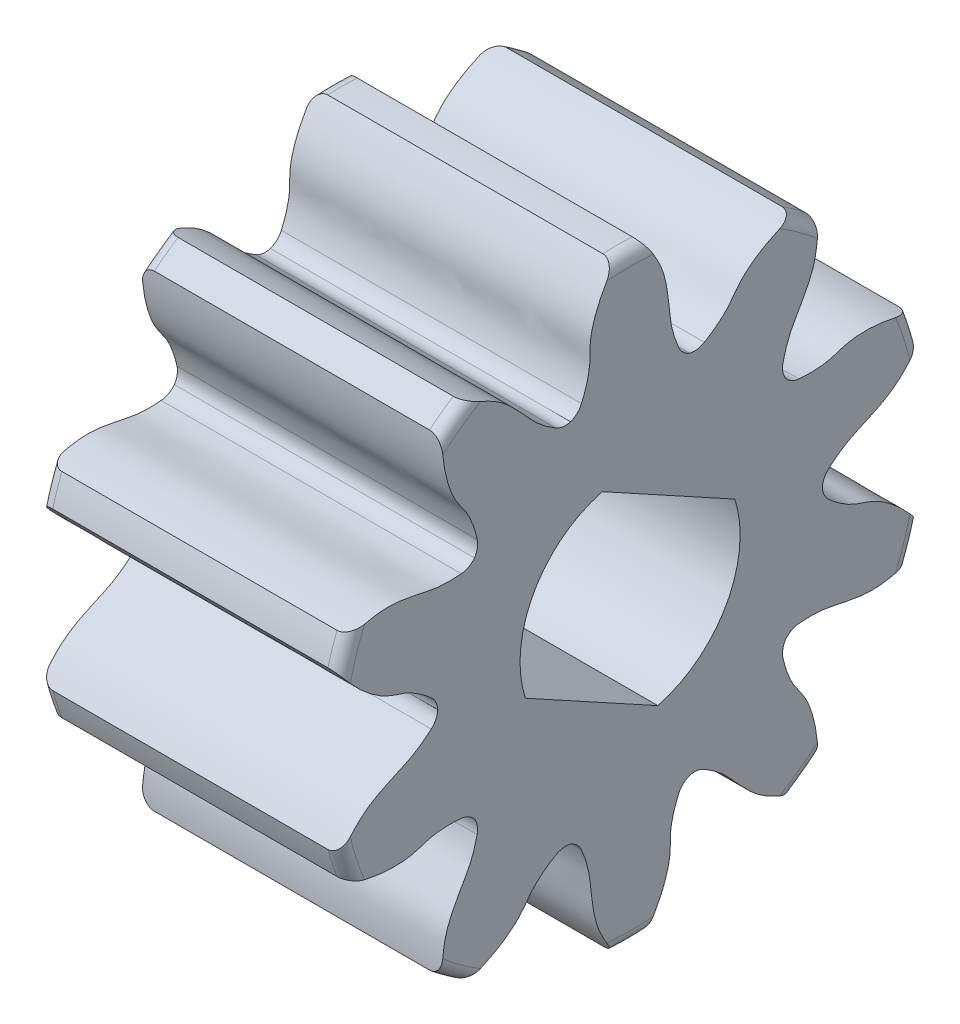
from build123d import *

# Parameters (mm, degrees)
SKETCH1_W           = 2.4
SKETCH1_H           = 2.4
CUT_EXTRUDE1_DEPTH  = 5.156921938
CUT_EXTRUDE2_DEPTH  = 5.156922111
CUT_EXTRUDE3_DEPTH  = 5.156922111
CUT_EXTRUDE4_DEPTH  = 5.156922111
CUT_EXTRUDE5_DEPTH  = 5.156922111
CUT_EXTRUDE6_DEPTH  = 5.156922111
CUT_EXTRUDE7_DEPTH  = 5.156922111
CUT_EXTRUDE8_DEPTH  = 5.156922111
CUT_EXTRUDE9_DEPTH  = 5.109057333
CUT_EXTRUDE10_DEPTH = 5.109057333
FILLET1_R           = 0.1
SCALE1_SCALE        = 2.5
CUT_EXTRUDE11_START = -6
CUT_EXTRUDE11_DEPTH = 6.000049


with BuildPart() as part:
    # Sketch1 → Revolve1 (revolve)
    with BuildSketch(Plane.XY, mode=Mode.PRIVATE) as revolve1_sk:
        with Locations((-0.8, 1.2)):
            Rectangle(SKETCH1_W, SKETCH1_H)
    revolve(revolve1_sk.sketch.rotate(Axis((-2, 0, 0), (1, 0, 0)), 270), axis=Axis((-2, 0, 0), (1, 0, 0)))

    # Sketch2 → Cut-Extrude1 (cut, through all)
    with BuildSketch(Plane.ZY.offset(2)):
        with BuildLine():
            ThreePointArc((1.313937156, 2.008374753), (0.741640786, 2.282535639), (0.117495572, 2.397122189))
            add(Edge.make_bspline(
                [(0.117495572, 2.397122189), (0.141774305, 2.363264737), (0.164667851, 2.32835723), (0.185846891, 2.292479211), (0.240081832, 2.200603365), (0.285141165, 2.100907601), (0.308300652, 1.996762327), (0.31987732, 1.944703519), (0.322889285, 1.890583293), (0.321092337, 1.837283109), (0.319288686, 1.783784122), (0.32833626, 1.729839367), (0.341837087, 1.678040503), (0.353675808, 1.632618674), (0.369800189, 1.588226107), (0.388574435, 1.545204885)],
                knots=[-0.000124084, -0.000124084, -0.000124084, -0.000124084, 0, 0, 0, 0.000320068, 0.000320068, 0.000320068, 0.000479179, 0.000479179, 0.000479179, 0.00063999, 0.00063999, 0.00063999, 0.000780383, 0.000780383, 0.000780383, 0.000780383], degree=3))
            ThreePointArc((0.388574435, 1.545204885), (0.423536077, 1.495046185), (0.475090004, 1.462176683))
            ThreePointArc((0.475090004, 1.462176683), (0.536118215, 1.45846603), (0.593885321, 1.478495334))
            add(Edge.make_bspline(
                [(0.593885321, 1.478495334), (0.660752303, 1.51776328), (0.724427265, 1.564713522), (0.777754321, 1.621010856), (0.876765521, 1.725536908), (0.96863274, 1.845157982), (1.095037654, 1.914083385), (1.128282244, 1.93221082), (1.162392991, 1.948826333), (1.197132178, 1.963892703), (1.235354952, 1.980469902), (1.274394337, 1.99525418), (1.313937156, 2.008374753)],
                knots=[0, 0, 0, 0, 0.000232634, 0.000232634, 0.000232634, 0.000660459, 0.000660459, 0.000660459, 0.000769687, 0.000769687, 0.000769687, 0.000890052, 0.000890052, 0.000890052, 0.000890052], degree=3))
        make_face()
    extrude(amount=-CUT_EXTRUDE1_DEPTH, mode=Mode.SUBTRACT)

    # Sketch3 → Cut-Extrude2 (cut, through all)
    with BuildSketch(Plane.ZY.offset(2)):
        with BuildLine():
            ThreePointArc((2.24349055, 0.852496424), (1.941640786, 1.410684605), (1.504048986, 1.870250424))
            add(Edge.make_bspline(
                [(1.504048986, 1.870250424), (1.503789982, 1.828588488), (1.501793131, 1.786891234), (1.497838764, 1.745416579), (1.487712486, 1.63920896), (1.465566552, 1.532068181), (1.423087915, 1.43420008), (1.401854237, 1.385279025), (1.372479897, 1.339724453), (1.339697073, 1.297659918), (1.306791974, 1.255438488), (1.282403683, 1.206478234), (1.262879473, 1.156636485), (1.245758918, 1.112930828), (1.232710521, 1.067538814), (1.222611965, 1.021698689)],
                knots=[-0.000124067, -0.000124067, -0.000124067, -0.000124067, 0, 0, 0, 0.000320068, 0.000320068, 0.000320068, 0.000479179, 0.000479179, 0.000479179, 0.00063999, 0.00063999, 0.00063999, 0.000780383, 0.000780383, 0.000780383, 0.000780383], degree=3))
            ThreePointArc((1.222611965, 1.021698689), (1.221413983, 0.960569511), (1.243801777, 0.903674887))
            ThreePointArc((1.243801777, 0.903674887), (1.290993571, 0.864801424), (1.349501071, 0.847050818))
            add(Edge.make_bspline(
                [(1.349501071, 0.847050818), (1.426678715, 0.839515828), (1.5057895, 0.840072168), (1.582022738, 0.854272811), (1.723563354, 0.88063884), (1.868196998, 0.923416125), (2.010974057, 0.904879004), (2.048524534, 0.900003726), (2.085887061, 0.893396165), (2.122847445, 0.885165932), (2.163514151, 0.876110385), (2.203787658, 0.865124342), (2.24349055, 0.852496424)],
                knots=[0, 0, 0, 0, 0.000232634, 0.000232634, 0.000232634, 0.000660459, 0.000660459, 0.000660459, 0.000769687, 0.000769687, 0.000769687, 0.000890048, 0.000890048, 0.000890048, 0.000890048], degree=3))
        make_face()
    extrude(amount=-CUT_EXTRUDE2_DEPTH, mode=Mode.SUBTRACT)

    # Sketch4 → Cut-Extrude3 (cut, through all)
    with BuildSketch(Plane.ZY.offset(2)):
        with BuildLine():
            ThreePointArc((2.316106807, -0.629006564), (2.4, 0), (2.316106807, 0.629006564))
            add(Edge.make_bspline(
                [(2.316106807, 0.629006564), (2.291408997, 0.595453589), (2.26528448, 0.56289352), (2.23770714, 0.531664139), (2.167087536, 0.451692447), (2.08619533, 0.378030789), (1.994303963, 0.323822149), (1.948370482, 0.296725027), (1.897829837, 0.277136408), (1.846583062, 0.262374745), (1.795145143, 0.247558023), (1.746636486, 0.222283423), (1.701544824, 0.193436643), (1.662004463, 0.168141233), (1.624767332, 0.139087979), (1.589653279, 0.107938321)],
                knots=[-0.000124063, -0.000124063, -0.000124063, -0.000124063, 0, 0, 0, 0.000320068, 0.000320068, 0.000320068, 0.000479179, 0.000479179, 0.000479179, 0.00063999, 0.00063999, 0.00063999, 0.000780383, 0.000780383, 0.000780383, 0.000780383], degree=3))
            ThreePointArc((1.589653279, 0.107938321), (1.552753262, 0.059187933), (1.537423547, 0))
            ThreePointArc((1.537423547, 0), (1.552753262, -0.059187933), (1.589653279, -0.107938321))
            add(Edge.make_bspline(
                [(1.589653279, -0.107938321), (1.647662348, -0.159398136), (1.711991327, -0.205448201), (1.78201224, -0.238768412), (1.912018567, -0.300633333), (2.0541735, -0.351039306), (2.158786721, -0.449958402), (2.186300079, -0.475974201), (2.212643171, -0.503280972), (2.23770714, -0.531664139), (2.26528448, -0.56289352), (2.291408997, -0.595453589), (2.316106807, -0.629006564)],
                knots=[0, 0, 0, 0, 0.000232634, 0.000232634, 0.000232634, 0.000660459, 0.000660459, 0.000660459, 0.000769687, 0.000769687, 0.000769687, 0.00089005, 0.00089005, 0.00089005, 0.00089005], degree=3))
        make_face()
    extrude(amount=-CUT_EXTRUDE3_DEPTH, mode=Mode.SUBTRACT)

    # Sketch5 → Cut-Extrude4 (cut, through all)
    with BuildSketch(Plane.ZY.offset(2)):
        with BuildLine():
            ThreePointArc((1.504048986, -1.870250424), (1.941640786, -1.410684606), (2.24349055, -0.852496424))
            add(Edge.make_bspline(
                [(2.24349055, -0.852496424), (2.203787658, -0.865124342), (2.163514151, -0.876110385), (2.122847445, -0.885165932), (2.018708804, -0.908355228), (1.909968398, -0.920401515), (1.803763682, -0.910244837), (1.750675426, -0.905167846), (1.698273284, -0.891308326), (1.648137084, -0.873128663), (1.597813883, -0.854881194), (1.543713518, -0.846816101), (1.490277886, -0.843649422), (1.443420793, -0.840872598), (1.396218246, -0.842489738), (1.349501071, -0.847050818)],
                knots=[-0.000124065, -0.000124065, -0.000124065, -0.000124065, 0, 0, 0, 0.000320068, 0.000320068, 0.000320068, 0.000479179, 0.000479179, 0.000479179, 0.00063999, 0.00063999, 0.00063999, 0.000780383, 0.000780383, 0.000780383, 0.000780383], degree=3))
            ThreePointArc((1.349501071, -0.847050818), (1.290993571, -0.864801424), (1.243801777, -0.903674887))
            ThreePointArc((1.243801777, -0.903674887), (1.221413983, -0.960569511), (1.222611965, -1.021698689))
            add(Edge.make_bspline(
                [(1.222611965, -1.021698689), (1.239294967, -1.09742743), (1.264270655, -1.17249434), (1.301333635, -1.240608218), (1.370147675, -1.367073791), (1.455525544, -1.491409653), (1.482016232, -1.632926991), (1.488983303, -1.670146161), (1.494244795, -1.707721884), (1.497838764, -1.745416579), (1.501793131, -1.786891234), (1.503789982, -1.828588488), (1.504048986, -1.870250424)],
                knots=[0, 0, 0, 0, 0.000232634, 0.000232634, 0.000232634, 0.000660459, 0.000660459, 0.000660459, 0.000769687, 0.000769687, 0.000769687, 0.000890052, 0.000890052, 0.000890052, 0.000890052], degree=3))
        make_face()
    extrude(amount=-CUT_EXTRUDE4_DEPTH, mode=Mode.SUBTRACT)

    # Sketch6 → Cut-Extrude5 (cut, through all)
    with BuildSketch(Plane.ZY.offset(2)):
        with BuildLine():
            ThreePointArc((0.117495572, -2.397122189), (0.741640786, -2.282535639), (1.313937156, -2.008374753))
            add(Edge.make_bspline(
                [(1.313937156, -2.008374753), (1.274394337, -1.99525418), (1.235354952, -1.980469902), (1.197132178, -1.963892703), (1.099251922, -1.92144208), (1.004198456, -1.867271724), (0.924246981, -1.796629232), (0.884281861, -1.761317367), (0.850034059, -1.719303573), (0.820158758, -1.675126599), (0.790172027, -1.63078485), (0.751144455, -1.592460657), (0.709775447, -1.558490083), (0.673499439, -1.528701677), (0.634361246, -1.502265009), (0.593885321, -1.478495334)],
                knots=[-0.000124067, -0.000124067, -0.000124067, -0.000124067, 0, 0, 0, 0.000320068, 0.000320068, 0.000320068, 0.000479179, 0.000479179, 0.000479179, 0.00063999, 0.00063999, 0.00063999, 0.000780383, 0.000780383, 0.000780383, 0.000780383], degree=3))
            ThreePointArc((0.593885321, -1.478495334), (0.536118215, -1.45846603), (0.475090004, -1.462176683))
            ThreePointArc((0.475090004, -1.462176683), (0.423536077, -1.495046185), (0.388574435, -1.545204885))
            add(Edge.make_bspline(
                [(0.388574435, -1.545204885), (0.357559031, -1.616276746), (0.333641564, -1.691687493), (0.323589812, -1.76857785), (0.30492694, -1.911338526), (0.300916302, -2.062112204), (0.239165914, -2.192172971), (0.222925514, -2.226379054), (0.205095694, -2.25987108), (0.185846891, -2.292479211), (0.164667851, -2.32835723), (0.141774305, -2.363264737), (0.117495572, -2.397122189)],
                knots=[0, 0, 0, 0, 0.000232634, 0.000232634, 0.000232634, 0.000660459, 0.000660459, 0.000660459, 0.000769687, 0.000769687, 0.000769687, 0.000890069, 0.000890069, 0.000890069, 0.000890069], degree=3))
        make_face()
    extrude(amount=-CUT_EXTRUDE5_DEPTH, mode=Mode.SUBTRACT)

    # Sketch7 → Cut-Extrude6 (cut, through all)
    with BuildSketch(Plane.ZY.offset(2)):
        with BuildLine():
            ThreePointArc((-1.313937156, -2.008374753), (-0.741640786, -2.282535639), (-0.117495572, -2.397122189))
            add(Edge.make_bspline(
                [(-0.117495572, -2.397122189), (-0.141774305, -2.363264737), (-0.164667851, -2.32835723), (-0.185846891, -2.292479211), (-0.240081832, -2.200603365), (-0.285141165, -2.100907601), (-0.308300652, -1.996762327), (-0.31987732, -1.944703519), (-0.322889285, -1.890583293), (-0.321092337, -1.837283109), (-0.319288686, -1.783784122), (-0.32833626, -1.729839367), (-0.341837087, -1.678040503), (-0.353675808, -1.632618674), (-0.369800189, -1.588226107), (-0.388574435, -1.545204885)],
                knots=[-0.000124084, -0.000124084, -0.000124084, -0.000124084, 0, 0, 0, 0.000320068, 0.000320068, 0.000320068, 0.000479179, 0.000479179, 0.000479179, 0.00063999, 0.00063999, 0.00063999, 0.000780383, 0.000780383, 0.000780383, 0.000780383], degree=3))
            ThreePointArc((-0.388574435, -1.545204885), (-0.423536077, -1.495046185), (-0.475090004, -1.462176683))
            ThreePointArc((-0.475090004, -1.462176683), (-0.536118215, -1.45846603), (-0.593885321, -1.478495334))
            add(Edge.make_bspline(
                [(-0.593885321, -1.478495334), (-0.660752303, -1.51776328), (-0.724427265, -1.564713522), (-0.777754321, -1.621010856), (-0.876765521, -1.725536908), (-0.96863274, -1.845157982), (-1.095037654, -1.914083385), (-1.128282244, -1.93221082), (-1.162392991, -1.948826333), (-1.197132178, -1.963892703), (-1.235354952, -1.980469902), (-1.274394337, -1.99525418), (-1.313937156, -2.008374753)],
                knots=[0, 0, 0, 0, 0.000232634, 0.000232634, 0.000232634, 0.000660459, 0.000660459, 0.000660459, 0.000769687, 0.000769687, 0.000769687, 0.000890052, 0.000890052, 0.000890052, 0.000890052], degree=3))
        make_face()
    extrude(amount=-CUT_EXTRUDE6_DEPTH, mode=Mode.SUBTRACT)

    # Sketch8 → Cut-Extrude7 (cut, through all)
    with BuildSketch(Plane.ZY.offset(2)):
        with BuildLine():
            ThreePointArc((-2.24349055, -0.852496424), (-1.941640786, -1.410684605), (-1.504048986, -1.870250424))
            add(Edge.make_bspline(
                [(-1.504048986, -1.870250424), (-1.503789982, -1.828588488), (-1.501793131, -1.786891234), (-1.497838764, -1.745416579), (-1.487712486, -1.63920896), (-1.465566552, -1.532068181), (-1.423087915, -1.43420008), (-1.401854237, -1.385279025), (-1.372479897, -1.339724453), (-1.339697073, -1.297659918), (-1.306791974, -1.255438488), (-1.282403683, -1.206478234), (-1.262879473, -1.156636485), (-1.245758918, -1.112930828), (-1.232710521, -1.067538814), (-1.222611965, -1.021698689)],
                knots=[-0.000124067, -0.000124067, -0.000124067, -0.000124067, 0, 0, 0, 0.000320068, 0.000320068, 0.000320068, 0.000479179, 0.000479179, 0.000479179, 0.00063999, 0.00063999, 0.00063999, 0.000780383, 0.000780383, 0.000780383, 0.000780383], degree=3))
            ThreePointArc((-1.222611965, -1.021698689), (-1.221413983, -0.960569511), (-1.243801777, -0.903674887))
            ThreePointArc((-1.243801777, -0.903674887), (-1.290993571, -0.864801424), (-1.349501071, -0.847050818))
            add(Edge.make_bspline(
                [(-1.349501071, -0.847050818), (-1.426678715, -0.839515828), (-1.505789501, -0.840072168), (-1.582022738, -0.854272811), (-1.723563354, -0.88063884), (-1.868196998, -0.923416125), (-2.010974057, -0.904879004), (-2.048524534, -0.900003726), (-2.085887061, -0.893396165), (-2.122847445, -0.885165932), (-2.163514151, -0.876110385), (-2.203787658, -0.865124342), (-2.24349055, -0.852496424)],
                knots=[0, 0, 0, 0, 0.000232634, 0.000232634, 0.000232634, 0.000660459, 0.000660459, 0.000660459, 0.000769687, 0.000769687, 0.000769687, 0.000890048, 0.000890048, 0.000890048, 0.000890048], degree=3))
        make_face()
    extrude(amount=-CUT_EXTRUDE7_DEPTH, mode=Mode.SUBTRACT)

    # Sketch9 → Cut-Extrude8 (cut, through all)
    with BuildSketch(Plane.ZY.offset(2)):
        with BuildLine():
            ThreePointArc((-2.316106807, 0.629006564), (-2.4, 0), (-2.316106807, -0.629006564))
            add(Edge.make_bspline(
                [(-2.316106807, -0.629006564), (-2.291408997, -0.595453589), (-2.26528448, -0.56289352), (-2.23770714, -0.531664139), (-2.167087536, -0.451692447), (-2.08619533, -0.378030789), (-1.994303963, -0.323822149), (-1.948370482, -0.296725027), (-1.897829837, -0.277136408), (-1.846583062, -0.262374745), (-1.795145143, -0.247558023), (-1.746636486, -0.222283423), (-1.701544824, -0.193436643), (-1.662004463, -0.168141233), (-1.624767332, -0.139087979), (-1.589653279, -0.107938321)],
                knots=[-0.000124063, -0.000124063, -0.000124063, -0.000124063, 0, 0, 0, 0.000320068, 0.000320068, 0.000320068, 0.000479179, 0.000479179, 0.000479179, 0.00063999, 0.00063999, 0.00063999, 0.000780383, 0.000780383, 0.000780383, 0.000780383], degree=3))
            ThreePointArc((-1.589653279, -0.107938321), (-1.552753262, -0.059187933), (-1.537423547, 0))
            ThreePointArc((-1.537423547, 0), (-1.552753262, 0.059187933), (-1.589653279, 0.107938321))
            add(Edge.make_bspline(
                [(-1.589653279, 0.107938321), (-1.647662348, 0.159398136), (-1.711991327, 0.205448201), (-1.78201224, 0.238768412), (-1.912018567, 0.300633333), (-2.0541735, 0.351039306), (-2.158786721, 0.449958402), (-2.186300079, 0.475974201), (-2.212643171, 0.503280972), (-2.23770714, 0.531664139), (-2.26528448, 0.56289352), (-2.291408997, 0.595453589), (-2.316106807, 0.629006564)],
                knots=[0, 0, 0, 0, 0.000232634, 0.000232634, 0.000232634, 0.000660459, 0.000660459, 0.000660459, 0.000769687, 0.000769687, 0.000769687, 0.00089005, 0.00089005, 0.00089005, 0.00089005], degree=3))
        make_face()
    extrude(amount=-CUT_EXTRUDE8_DEPTH, mode=Mode.SUBTRACT)

    # Sketch10 → Cut-Extrude9 (cut, through all)
    with BuildSketch(Plane.ZY.offset(2)):
        with BuildLine():
            ThreePointArc((-1.504048986, 1.870250424), (-1.941640786, 1.410684606), (-2.24349055, 0.852496424))
            add(Edge.make_bspline(
                [(-2.24349055, 0.852496424), (-2.203787658, 0.865124342), (-2.163514151, 0.876110385), (-2.122847445, 0.885165932), (-2.018708804, 0.908355228), (-1.909968398, 0.920401515), (-1.803763682, 0.910244837), (-1.750675426, 0.905167846), (-1.698273284, 0.891308326), (-1.648137084, 0.873128663), (-1.597813883, 0.854881194), (-1.543713518, 0.846816101), (-1.490277886, 0.843649422), (-1.443420793, 0.840872598), (-1.396218246, 0.842489738), (-1.349501071, 0.847050818)],
                knots=[-0.000124065, -0.000124065, -0.000124065, -0.000124065, 0, 0, 0, 0.000320068, 0.000320068, 0.000320068, 0.000479179, 0.000479179, 0.000479179, 0.00063999, 0.00063999, 0.00063999, 0.000780383, 0.000780383, 0.000780383, 0.000780383], degree=3))
            ThreePointArc((-1.349501071, 0.847050818), (-1.290993571, 0.864801424), (-1.243801777, 0.903674887))
            ThreePointArc((-1.243801777, 0.903674887), (-1.221413983, 0.960569511), (-1.222611965, 1.021698689))
            add(Edge.make_bspline(
                [(-1.222611965, 1.021698689), (-1.239294967, 1.09742743), (-1.264270655, 1.17249434), (-1.301333635, 1.240608218), (-1.370147675, 1.367073791), (-1.455525544, 1.491409653), (-1.482016232, 1.632926991), (-1.488983303, 1.670146161), (-1.494244795, 1.707721884), (-1.497838764, 1.745416579), (-1.501793131, 1.786891234), (-1.503789982, 1.828588488), (-1.504048986, 1.870250424)],
                knots=[0, 0, 0, 0, 0.000232634, 0.000232634, 0.000232634, 0.000660459, 0.000660459, 0.000660459, 0.000769687, 0.000769687, 0.000769687, 0.000890052, 0.000890052, 0.000890052, 0.000890052], degree=3))
        make_face()
    extrude(amount=-CUT_EXTRUDE9_DEPTH, mode=Mode.SUBTRACT)

    # Sketch11 → Cut-Extrude10 (cut, through all)
    with BuildSketch(Plane.ZY.offset(2)):
        with BuildLine():
            ThreePointArc((-0.117495572, 2.397122189), (-0.741640786, 2.282535639), (-1.313937156, 2.008374753))
            add(Edge.make_bspline(
                [(-1.313937156, 2.008374753), (-1.274394337, 1.99525418), (-1.235354952, 1.980469902), (-1.197132178, 1.963892703), (-1.099251922, 1.92144208), (-1.004198456, 1.867271724), (-0.924246981, 1.796629232), (-0.884281861, 1.761317367), (-0.850034059, 1.719303573), (-0.820158758, 1.675126599), (-0.790172027, 1.63078485), (-0.751144455, 1.592460657), (-0.709775447, 1.558490083), (-0.673499439, 1.528701677), (-0.634361246, 1.502265009), (-0.593885321, 1.478495334)],
                knots=[-0.000124067, -0.000124067, -0.000124067, -0.000124067, 0, 0, 0, 0.000320068, 0.000320068, 0.000320068, 0.000479179, 0.000479179, 0.000479179, 0.00063999, 0.00063999, 0.00063999, 0.000780383, 0.000780383, 0.000780383, 0.000780383], degree=3))
            ThreePointArc((-0.593885321, 1.478495334), (-0.536118215, 1.45846603), (-0.475090004, 1.462176683))
            ThreePointArc((-0.475090004, 1.462176683), (-0.423536077, 1.495046185), (-0.388574435, 1.545204885))
            add(Edge.make_bspline(
                [(-0.388574435, 1.545204885), (-0.357559031, 1.616276746), (-0.333641564, 1.691687493), (-0.323589812, 1.76857785), (-0.30492694, 1.911338526), (-0.300916302, 2.062112204), (-0.239165914, 2.192172971), (-0.222925514, 2.226379054), (-0.205095694, 2.25987108), (-0.185846891, 2.292479211), (-0.164667851, 2.32835723), (-0.141774305, 2.363264737), (-0.117495572, 2.397122189)],
                knots=[0, 0, 0, 0, 0.000232634, 0.000232634, 0.000232634, 0.000660459, 0.000660459, 0.000660459, 0.000769687, 0.000769687, 0.000769687, 0.000890069, 0.000890069, 0.000890069, 0.000890069], degree=3))
        make_face()
    extrude(amount=-CUT_EXTRUDE10_DEPTH, mode=Mode.SUBTRACT)

    # Fillet1
    fillet1_edges = [part.edges().sort_by_distance(p)[0] for p in [
        (-2, 1.941640786, 1.410684606),
        (0.4, -1.941640787, 1.410684605),
        (-2, 1.941640787, -1.410684605),
        (0.4, 0.741640786, -2.282535639),
        (-2, -2.4, 0),
        (0.4, 0.741640786, 2.282535639),
        (0.4, -1.941640786, -1.410684606),
        (0.4, 2.4, 0),
        (-2, -0.741640786, 2.282535639),
        (-2, -0.741640786, -2.282535639),
        (0.4, 1.941640786, 1.410684606),
        (0.4, -0.741640786, 2.282535639),
        (0.4, -2.4, 0),
        (0.4, -0.741640786, -2.282535639),
        (0.4, 1.941640787, -1.410684605),
        (-2, 2.4, 0),
        (-2, 0.741640786, 2.282535639),
        (-2, -1.941640787, 1.410684605),
        (-2, -1.941640786, -1.410684606),
        (-2, 0.741640786, -2.282535639),
    ]]
    fillet(fillet1_edges, radius=FILLET1_R)


with BuildPart() as part_1:
    # Scale1: scaled about (-0.800028896, 4.4307e-05, -5e-09)
    add(part.part.scale(SCALE1_SCALE).moved(Location((1.200043344, -6.6461e-05, 8e-09))))

    # Sketch14 → Cut-Extrude11 (cut)
    with BuildSketch(Plane(origin=(2.199994536, 0, 0), x_dir=(0, 0, -1), z_dir=(1, 0, 0)).offset(CUT_EXTRUDE11_START)):
        Polygon((-0.554510357, 2.128971175), (2.093326493, 0.676745293), (0.554510357, -2.128971175), (-2.093326493, -0.676745293), align=None)
        with BuildLine():
            Line((-2.093326493, -0.676745293), (-0.554510357, 2.128971175))
            ThreePointArc((-0.554510357, 2.128971175), (-1.928930072, 1.057936094), (-2.093326493, -0.676745293))
        make_face()
        with BuildLine():
            ThreePointArc((2.093326493, 0.676745293), (1.928930072, -1.057936094), (0.554510357, -2.128971175))
            Line((0.554510357, -2.128971175), (2.093326493, 0.676745293))
        make_face()
    extrude(amount=CUT_EXTRUDE11_DEPTH, mode=Mode.SUBTRACT)


solid = part_1.part
